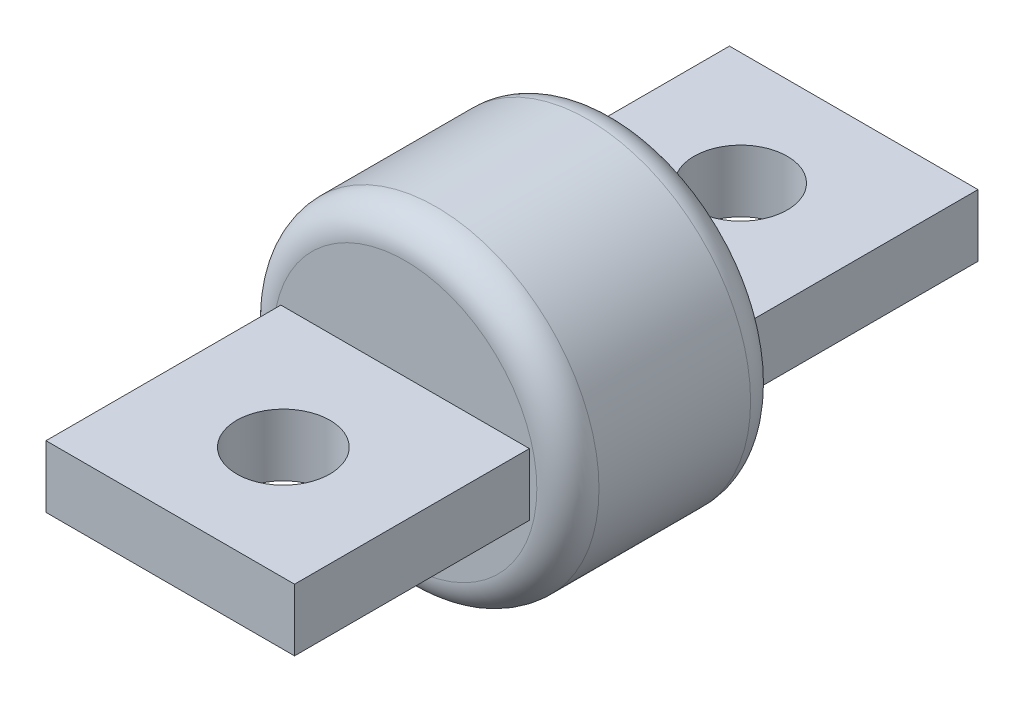
from build123d import *

# Parameters (mm, degrees)
SKETCH1_R           = 16.637
BOSS_EXTRUDE1_DEPTH = 21.844
SKETCH2_W           = 25.4
SKETCH2_H           = 6.35
BOSS_EXTRUDE2_DEPTH = 24.003
SKETCH3_W           = 25.4
SKETCH3_H           = 6.35
BOSS_EXTRUDE3_DEPTH = 24.003
SKETCH4_R           = 4.7625
CUT_EXTRUDE1_DEPTH  = 53.64268726
FILLET1_R           = 3.175


with BuildPart() as part:
    # Sketch1 → Boss-Extrude1 (new body)
    with BuildSketch(Plane.XY):
        Circle(SKETCH1_R)
    extrude(amount=BOSS_EXTRUDE1_DEPTH)

    # Sketch2 → Boss-Extrude2 (add)
    with BuildSketch(Plane.XY.offset(21.844)):
        Rectangle(SKETCH2_W, SKETCH2_H)
    extrude(amount=BOSS_EXTRUDE2_DEPTH)

    # Sketch3 → Boss-Extrude3 (add)
    with BuildSketch(Plane(origin=(0, 0, 0), x_dir=(-1, 0, 0), z_dir=(0, 0, -1))):
        Rectangle(SKETCH3_W, SKETCH3_H)
    extrude(amount=BOSS_EXTRUDE3_DEPTH)

    # Sketch4 → Cut-Extrude1 (cut, through all)
    with BuildSketch(Plane(origin=(0, 3.175, 0), x_dir=(1, 0, 0), z_dir=(0, 1, 0))):
        with Locations((0, 12.446)):
            Circle(SKETCH4_R)
        with Locations((0, -34.29)):
            Circle(SKETCH4_R)
    extrude(amount=-CUT_EXTRUDE1_DEPTH, mode=Mode.SUBTRACT)

    # Fillet1
    fillet1_edges = [part.edges().sort_by_distance(p)[0] for p in [
        (-16.637, 0, 0),
        (-16.637, 0, 21.844),
    ]]
    fillet(fillet1_edges, radius=FILLET1_R)


solid = part.part
